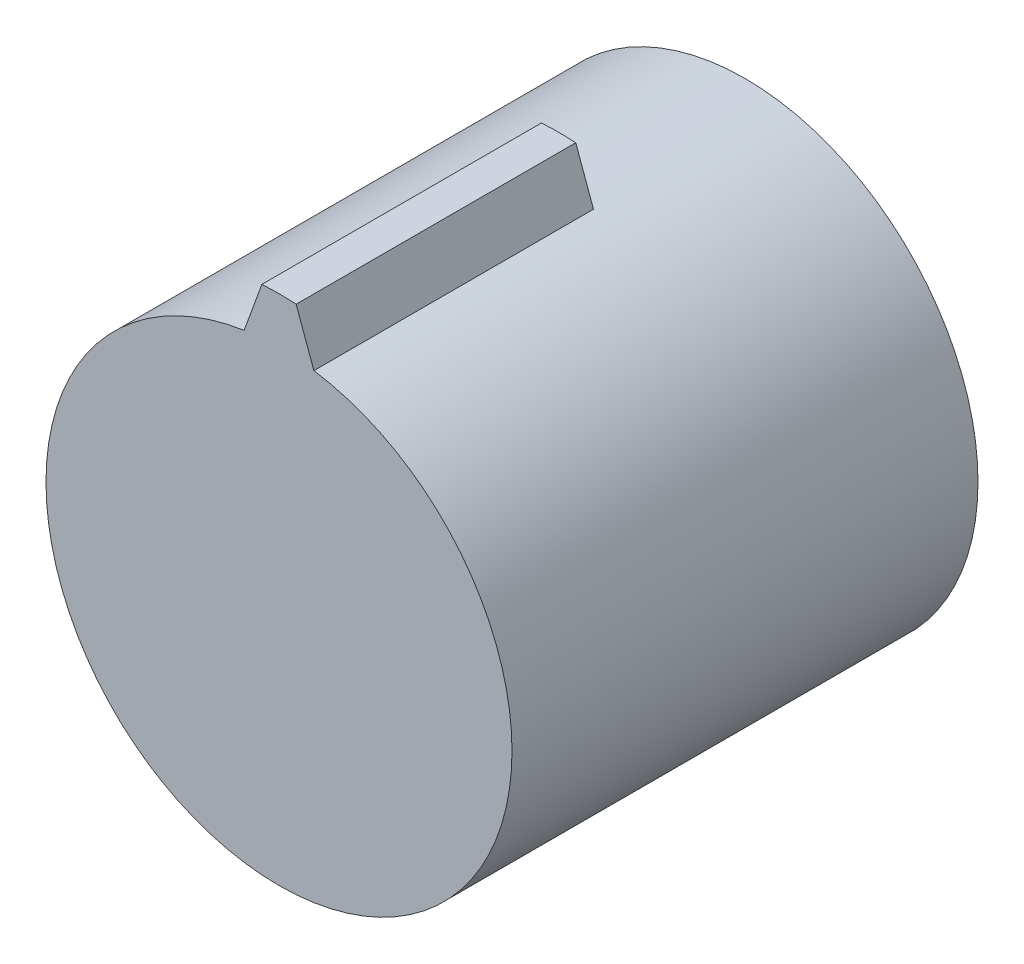
from build123d import *

# Parameters (mm, degrees)
SKETCH_1_R      = 2.5
EXTRUDE_1_DEPTH = 5
EXTRUDE_2_DEPTH = 3


with BuildPart() as part:
    # 草图1 → 凸台-拉伸1 (new body)
    with BuildSketch(Plane.XY):
        Circle(SKETCH_1_R)
    extrude(amount=EXTRUDE_1_DEPTH)

    # 草图2 → 凸台-拉伸2 (add)
    with BuildSketch(Plane.XY.offset(5)):
        with BuildLine():
            Line((-0.184041749, 2.994349451), (-0.374222232, 2.471832867))
            ThreePointArc((-0.374222232, 2.471832867), (0, 2.5), (0.374222232, 2.471832867))
            Line((0.374222232, 2.471832867), (0.184041749, 2.994349451))
            ThreePointArc((0.184041749, 2.994349451), (0, 3), (-0.184041749, 2.994349451))
        make_face()
    extrude(amount=-EXTRUDE_2_DEPTH)


solid = part.part
